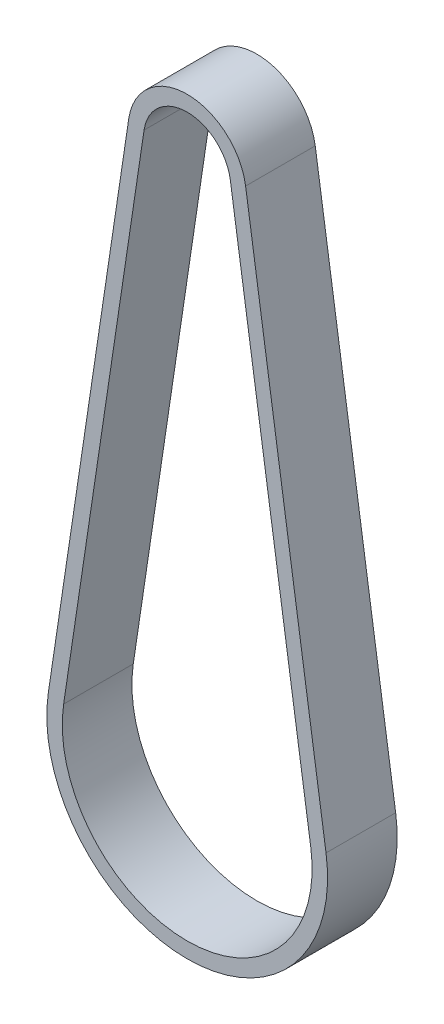
from build123d import *

# Parameters (mm, degrees)
EXTRUDE_THIN1_DEPTH = 4.5


with BuildPart() as part:
    # Sketch1 → Extrude-Thin1 (new body, symmetric)
    with BuildSketch(Plane.XY):
        with BuildLine():
            Line((17.945099167, -68.314028873), (7.550886312, 1.13019507))
            ThreePointArc((7.550886312, 1.13019507), (0, 7.635), (-7.550886312, 1.13019507))
            Line((-7.550886312, 1.13019507), (-17.945099167, -68.314028873))
            ThreePointArc((-17.945099167, -68.314028873), (0, -89.145), (17.945099167, -68.314028873))
        make_face()
        with BuildLine():
            Line((15.967132877, -68.610085211), (5.572920022, 0.834138732))
            ThreePointArc((5.572920022, 0.834138732), (0, 5.635), (-5.572920022, 0.834138732))
            Line((-5.572920022, 0.834138732), (-15.967132877, -68.610085211))
            ThreePointArc((-15.967132877, -68.610085211), (0, -87.145), (15.967132877, -68.610085211))
        make_face(mode=Mode.SUBTRACT)
    extrude(amount=EXTRUDE_THIN1_DEPTH, both=True)


solid = part.part
